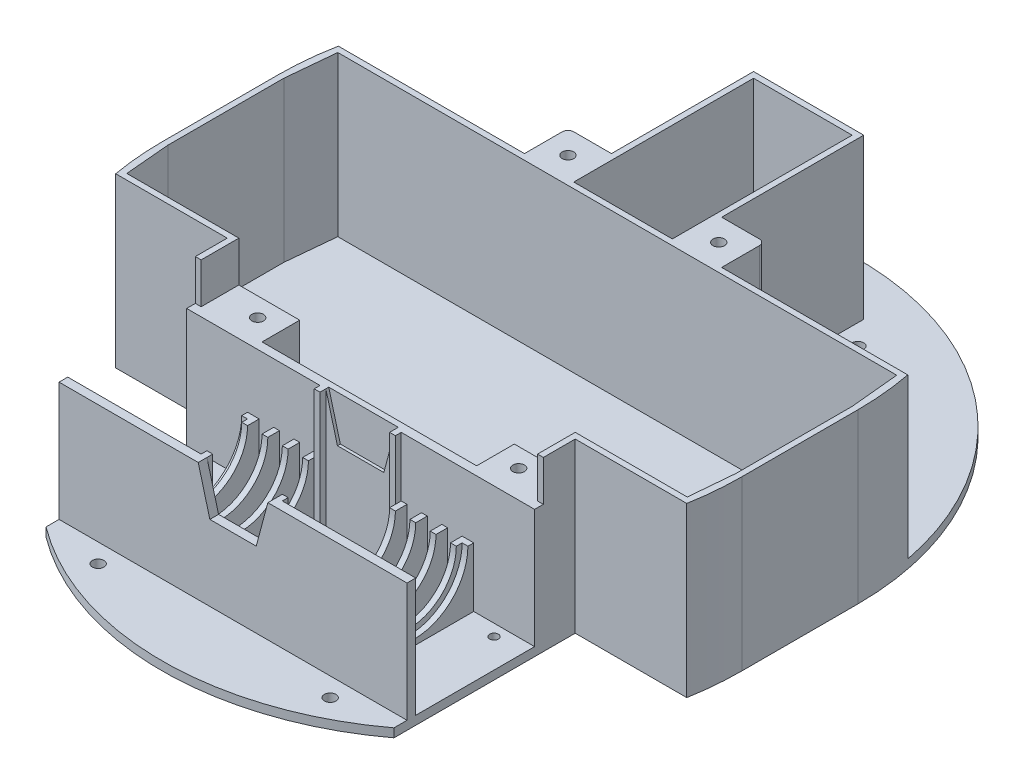
from build123d import *

# Parameters (mm, degrees)
EXTRUDE_1271_DEPTH           = 3
CUT_EXTRUDE_1634_DEPTH       = 3
SKETCH_3_W                   = 34
SKETCH_3_H                   = 62
CUT_EXTRUDE_1874_DEPTH       = 3
SKETCH_4_W                   = 120
SKETCH_4_H                   = 3
EXTRUDE_2348_DEPTH           = 41
SKETCH_5_W                   = 4
SKETCH_5_H                   = 41
SKETCH_5_W_2                 = 2
EXTRUDE_3692_DEPTH           = 20.5
SKETCH_10_R                  = 1.5
CUT_EXTRUDE_4123_DEPTH       = 177.864354803
CUT_EXTRUDE_4368_DEPTH       = 2
CUT_EXTRUDE_4605_DEPTH       = 2
SKETCH_11_R                  = 16.5
CUT_EXTRUDE_4720_DEPTH       = 23
SKETCH_12_R                  = 16.5
CUT_EXTRUDE_4849_DEPTH       = 23
CUT_EXTRUDE_5113_DEPTH       = 45
SKETCH_14_W                  = 2
SKETCH_14_H                  = 2
EXTRUDE_5954_DEPTH           = 41
SKETCH_19_W                  = 5
SKETCH_19_H                  = 41
CUT_EXTRUDE_6417_DEPTH       = 3
EXTRUDE_8763_DEPTH           = 55
EXTRUDE_9330_DEPTH           = 55
EXTRUDE_9736_DEPTH           = 2
EXTRUDE_10110_DEPTH          = 2
SKETCH_22_R                  = 2.5
CUT_EXTRUDE_10276_DEPTH      = 42
EXTRUDE_10908_DEPTH          = 55
SKETCH_26_W                  = 21
SKETCH_26_H                  = 13
EXTRUDE_11207_DEPTH          = 41
SKETCH_23_R                  = 2
CUT_EXTRUDE_12071_DEPTH      = 55
CUT_EXTRUDE_12071_DEPTH_BACK = 3


with BuildPart() as part:
    # 草图1 → Extrude 1271 (new body)
    with BuildSketch(Plane(origin=(0, 0, 0), x_dir=(1, 0, 0), z_dir=(0, 1, 0))):
        with BuildLine():
            ThreePointArc((-97.979589711, 20), (-99.493615301, 10.050896201), (-100, 0))
            Line((-100, 0), (-91.651513899, 0))
            ThreePointArc((-91.651513899, 0), (-95.341433092, 9.833609167), (-97.979589711, 20))
        make_face()
        with BuildLine():
            Line((-91.651513899, 0), (-100, 0))
            ThreePointArc((-100, 0), (0, -100), (100, 0))
            Line((100, 0), (91.651513899, 0))
            ThreePointArc((91.651513899, 0), (0, -60), (-91.651513899, 0))
        make_face()
        with BuildLine():
            Line((91.651513899, 0), (100, 0))
            ThreePointArc((100, 0), (99.493615301, 10.050896201), (97.979589711, 20))
            ThreePointArc((97.979589711, 20), (95.341433092, 9.833609167), (91.651513899, 0))
        make_face()
        with BuildLine():
            ThreePointArc((-97.979589711, 20), (-95.341433092, 9.833609167), (-91.651513899, 0))
            Line((-91.651513899, 0), (91.651513899, 0))
            ThreePointArc((91.651513899, 0), (95.341433092, 9.833609167), (97.979589711, 20))
            ThreePointArc((97.979589711, 20), (95.341433092, 30.166390833), (91.651513899, 40))
            Line((91.651513899, 40), (-91.651513899, 40))
            ThreePointArc((-91.651513899, 40), (-95.341433092, 30.166390833), (-97.979589711, 20))
        make_face()
        with BuildLine():
            ThreePointArc((100, 40), (0, 140), (-100, 40))
            Line((-100, 40), (-91.651513899, 40))
            ThreePointArc((-91.651513899, 40), (0, 100), (91.651513899, 40))
            Line((91.651513899, 40), (100, 40))
        make_face()
        with BuildLine():
            Line((-91.651513899, 40), (-100, 40))
            ThreePointArc((-100, 40), (-99.493615301, 29.949103799), (-97.979589711, 20))
            ThreePointArc((-97.979589711, 20), (-95.341433092, 30.166390833), (-91.651513899, 40))
        make_face()
        with BuildLine():
            ThreePointArc((97.979589711, 20), (99.493615301, 29.949103799), (100, 40))
            Line((100, 40), (91.651513899, 40))
            ThreePointArc((91.651513899, 40), (95.341433092, 30.166390833), (97.979589711, 20))
        make_face()
        with BuildLine():
            ThreePointArc((91.651513899, 40), (0, 100), (-91.651513899, 40))
            Line((-91.651513899, 40), (91.651513899, 40))
        make_face()
        with BuildLine():
            Line((91.651513899, 0), (-91.651513899, 0))
            ThreePointArc((-91.651513899, 0), (0, -60), (91.651513899, 0))
        make_face()
        with BuildLine():
            ThreePointArc((97.979589711, 20), (99.493615301, 10.050896201), (100, 0))
            Line((100, 0), (100, 40))
            ThreePointArc((100, 40), (99.493615301, 29.949103799), (97.979589711, 20))
        make_face()
        with BuildLine():
            Line((-100, 40), (-100, 0))
            ThreePointArc((-100, 0), (-99.493615301, 10.050896201), (-97.979589711, 20))
            ThreePointArc((-97.979589711, 20), (-99.493615301, 29.949103799), (-100, 40))
        make_face()
    extrude(amount=EXTRUDE_1271_DEPTH)

    # 草图2 → Cut-Extrude 1634 (cut)
    with BuildSketch(Plane(origin=(0, 3, 0), x_dir=(1, 0, 0), z_dir=(0, 1, 0))):
        with BuildLine():
            ThreePointArc((-98.456843338, -17.5), (-85.168687322, -52.40510185), (-60, -80))
            Line((-60, -80), (-60, -17.5))
            Line((-60, -17.5), (-98.456843338, -17.5))
        make_face()
        with BuildLine():
            Line((98.456843338, -17.5), (60, -17.5))
            Line((60, -17.5), (60, -80))
            ThreePointArc((60, -80), (85.168687322, -52.40510185), (98.456843338, -17.5))
        make_face()
    extrude(amount=-CUT_EXTRUDE_1634_DEPTH, mode=Mode.SUBTRACT)

    # 草图3 → Cut-Extrude 1874 (cut)
    with BuildSketch(Plane(origin=(0, 3, 0), x_dir=(1, 0, 0), z_dir=(0, 1, 0))):
        with Locations((0, 90)):
            Rectangle(SKETCH_3_W, SKETCH_3_H)
    extrude(amount=-CUT_EXTRUDE_1874_DEPTH, mode=Mode.SUBTRACT)

    # 草图4 → Extrude 2348 (add)
    with BuildSketch(Plane(origin=(0, 3, 0), x_dir=(1, 0, 0), z_dir=(0, 1, 0))):
        with Locations((0, -74)):
            Rectangle(SKETCH_4_W, SKETCH_4_H)
        with Locations((0, -30)):
            Rectangle(SKETCH_4_W, SKETCH_4_H)
    extrude(amount=EXTRUDE_2348_DEPTH)

    # 草图5 → Extrude 3692 (add)
    with BuildSketch(Plane(origin=(0, 3, 0), x_dir=(1, 0, 0), z_dir=(0, 1, 0))):
        with Locations((-37, -52)):
            Rectangle(SKETCH_5_W, SKETCH_5_H)
        with Locations((37, -52)):
            Rectangle(SKETCH_5_W, SKETCH_5_H)
        with Locations((-22, -52)):
            Rectangle(SKETCH_5_W_2, SKETCH_5_H)
        with Locations((-15, -52)):
            Rectangle(SKETCH_5_W_2, SKETCH_5_H)
        with Locations((22, -52)):
            Rectangle(SKETCH_5_W_2, SKETCH_5_H)
        with Locations((29, -52)):
            Rectangle(SKETCH_5_W_2, SKETCH_5_H)
        with Locations((-29, -52)):
            Rectangle(SKETCH_5_W_2, SKETCH_5_H)
        with Locations((15, -52)):
            Rectangle(SKETCH_5_W_2, SKETCH_5_H)
    extrude(amount=EXTRUDE_3692_DEPTH)

    # 草图10 → Cut-Extrude 4123 (cut, through all)
    with BuildSketch(Plane(origin=(0, 3, 0), x_dir=(1, 0, 0), z_dir=(0, 1, 0))):
        with Locations(Location((-50, -35.5, 0), (0, 0, 270))):
            Circle(SKETCH_10_R)
        with Locations(Location((-50, -68.5, 0), (0, 0, 270))):
            Circle(SKETCH_10_R)
        with Locations(Location((50, -35.5, 0), (0, 0, 270))):
            Circle(SKETCH_10_R)
        with Locations(Location((50, -68.5, 0), (0, 0, 270))):
            Circle(SKETCH_10_R)
    extrude(amount=-CUT_EXTRUDE_4123_DEPTH, mode=Mode.SUBTRACT)

    # 草图6 → Cut-Extrude 4368 (cut)
    with BuildSketch(Plane.ZY.offset(39)):
        with BuildLine():
            Line((33.5, 23.5), (70.5, 23.5))
            ThreePointArc((70.5, 23.5), (52, 42), (33.5, 23.5))
        make_face()
        with BuildLine():
            ThreePointArc((33.5, 23.5), (52, 5), (70.5, 23.5))
            Line((70.5, 23.5), (33.5, 23.5))
        make_face()
    extrude(amount=-CUT_EXTRUDE_4368_DEPTH, mode=Mode.SUBTRACT)

    # 草图8 → Cut-Extrude 4605 (cut)
    with BuildSketch(Plane(origin=(39, 0, 0), x_dir=(0, 0, -1), z_dir=(1, 0, 0))):
        with BuildLine():
            Line((-70.5, 23.5), (-33.5, 23.5))
            ThreePointArc((-33.5, 23.5), (-52, 42), (-70.5, 23.5))
        make_face()
        with BuildLine():
            ThreePointArc((-70.5, 23.5), (-52, 5), (-33.5, 23.5))
            Line((-33.5, 23.5), (-70.5, 23.5))
        make_face()
    extrude(amount=-CUT_EXTRUDE_4605_DEPTH, mode=Mode.SUBTRACT)

    # 草图11 → Cut-Extrude 4720 (cut)
    with BuildSketch(Plane.ZY.offset(37)):
        with Locations((52, 23.5)):
            Circle(SKETCH_11_R)
    extrude(amount=-CUT_EXTRUDE_4720_DEPTH, mode=Mode.SUBTRACT)

    # 草图12 → Cut-Extrude 4849 (cut)
    with BuildSketch(Plane(origin=(37, 0, 0), x_dir=(0, 0, -1), z_dir=(1, 0, 0))):
        with Locations((-52, 23.5)):
            Circle(SKETCH_12_R)
    extrude(amount=-CUT_EXTRUDE_4849_DEPTH, mode=Mode.SUBTRACT)

    # 草图13 → Cut-Extrude 5113 (cut)
    with BuildSketch(Plane.XY.offset(75.5)):
        Polygon((-8, 29), (8, 29), (12, 44), (-12, 44), align=None)
    extrude(amount=-CUT_EXTRUDE_5113_DEPTH, mode=Mode.SUBTRACT)

    # 草图14 → Extrude 5954 (add)
    with BuildSketch(Plane(origin=(0, 3, 0), x_dir=(1, 0, 0), z_dir=(0, 1, 0))):
        with Locations((-13, -32.5)):
            Rectangle(SKETCH_14_W, SKETCH_14_H)
        with Locations((13, -32.5)):
            Rectangle(SKETCH_14_W, SKETCH_14_H)
        with Locations((13, -71.5)):
            Rectangle(SKETCH_14_W, SKETCH_14_H)
        with Locations((-13, -71.5)):
            Rectangle(SKETCH_14_W, SKETCH_14_H)
    extrude(amount=EXTRUDE_5954_DEPTH)

    # 草图19 → Cut-Extrude 6417 (cut)
    with BuildSketch(Plane(origin=(0, 3, 0), x_dir=(1, 0, 0), z_dir=(0, 1, 0))):
        with Locations((-32.5, -52)):
            Rectangle(SKETCH_19_W, SKETCH_19_H)
        with Locations((-25.5, -52)):
            Rectangle(SKETCH_19_W, SKETCH_19_H)
        with Locations((-18.5, -52)):
            Rectangle(SKETCH_19_W, SKETCH_19_H)
        with Locations((18.5, -52)):
            Rectangle(SKETCH_19_W, SKETCH_19_H)
        with Locations((25.5, -52)):
            Rectangle(SKETCH_19_W, SKETCH_19_H)
        with Locations((32.5, -52)):
            Rectangle(SKETCH_19_W, SKETCH_19_H)
    extrude(amount=-CUT_EXTRUDE_6417_DEPTH, mode=Mode.SUBTRACT)

    # 草图15 → Extrude 8763 (add)
    with BuildSketch(Plane(origin=(0, 3, 0), x_dir=(1, 0, 0), z_dir=(0, 1, 0))):
        with BuildLine():
            Line((-96.633204099, -15.5), (-98, 0))
            Line((-98, 0), (-98, 40))
            Line((-98, 40), (-96.370155449, 57))
            Line((-96.370155449, 57), (96.370155449, 57))
            Line((96.370155449, 57), (98, 40))
            Line((98, 40), (98, 0))
            Line((98, 0), (96.633204099, -15.5))
            Line((96.633204099, -15.5), (58, -15.5))
            Line((58, -15.5), (58, -28.5))
            Line((58, -28.5), (60, -28.5))
            Line((60, -28.5), (60, -17.5))
            Line((60, -17.5), (98.456843338, -17.5))
            ThreePointArc((98.456843338, -17.5), (99.613463783, -8.78395316), (100, 0))
            Line((100, 0), (100, 40))
            ThreePointArc((100, 40), (99.543560573, 49.543560573), (98.178409032, 59))
            Line((98.178409032, 59), (-98.178409032, 59))
            ThreePointArc((-98.178409032, 59), (-99.543560573, 49.543560573), (-100, 40))
            Line((-100, 40), (-100, 0))
            ThreePointArc((-100, 0), (-99.613463783, -8.78395316), (-98.456843338, -17.5))
            Line((-98.456843338, -17.5), (-60, -17.5))
            Line((-60, -17.5), (-60, -28.5))
            Line((-60, -28.5), (-58, -28.5))
            Line((-58, -28.5), (-58, -15.5))
            Line((-58, -15.5), (-96.633204099, -15.5))
        make_face()
    extrude(amount=EXTRUDE_8763_DEPTH)

    # 草图16 → Extrude 9330 (add)
    with BuildSketch(Plane(origin=(0, 3, 0), x_dir=(1, 0, 0), z_dir=(0, 1, 0))):
        Polygon((-19, 123), (-19, 59), (-17, 59), (-17, 121), (17, 121), (17, 59), (19, 59), (19, 123), align=None)
    extrude(amount=EXTRUDE_9330_DEPTH)

    # 草图20 → Extrude 9736 (add)
    with BuildSketch(Plane.ZY.offset(19)):
        with BuildLine():
            ThreePointArc((-82.5, 13), (-90, 20.5), (-97.5, 13))
            Line((-97.5, 13), (-82.5, 13))
        make_face()
        with BuildLine():
            Line((-82.5, 13), (-97.5, 13))
            ThreePointArc((-97.5, 13), (-90, 5.5), (-82.5, 13))
        make_face()
        with BuildLine():
            ThreePointArc((-82.5, 13), (-90, 5.5), (-97.5, 13))
            Line((-97.5, 13), (-97.5, 3))
            Line((-97.5, 3), (-82.5, 3))
            Line((-82.5, 3), (-82.5, 13))
        make_face()
    extrude(amount=EXTRUDE_9736_DEPTH)

    # 草图21 → Extrude 10110 (add)
    with BuildSketch(Plane(origin=(19, 0, 0), x_dir=(0, 0, -1), z_dir=(1, 0, 0))):
        with BuildLine():
            ThreePointArc((97.5, 13), (90, 20.5), (82.5, 13))
            Line((82.5, 13), (97.5, 13))
        make_face()
        with BuildLine():
            Line((97.5, 13), (82.5, 13))
            ThreePointArc((82.5, 13), (90, 5.5), (97.5, 13))
        make_face()
        with BuildLine():
            ThreePointArc((97.5, 13), (90, 5.5), (82.5, 13))
            Line((82.5, 13), (82.5, 3))
            Line((82.5, 3), (97.5, 3))
            Line((97.5, 3), (97.5, 13))
        make_face()
    extrude(amount=EXTRUDE_10110_DEPTH)

    # 草图22 → Cut-Extrude 10276 (cut)
    with BuildSketch(Plane.ZY.offset(21)):
        with Locations((-90, 13)):
            Circle(SKETCH_22_R)
    extrude(amount=-CUT_EXTRUDE_10276_DEPTH, mode=Mode.SUBTRACT)

    # 草图25 → Extrude 10908 (add)
    with BuildSketch(Plane(origin=(0, 3, 0), x_dir=(1, 0, 0), z_dir=(0, 1, 0))):
        with BuildLine():
            Line((-19, 59), (-34, 59))
            Line((-34, 59), (-34, 72))
            ThreePointArc((-34, 72), (-33.414213562, 73.414213562), (-32, 74))
            Line((-32, 74), (-19, 74))
            Line((-19, 74), (-19, 59))
        make_face()
        with BuildLine():
            Line((19, 59), (34, 59))
            Line((34, 59), (34, 72))
            ThreePointArc((34, 72), (33.414213562, 73.414213562), (32, 74))
            Line((32, 74), (19, 74))
            Line((19, 74), (19, 59))
        make_face()
    extrude(amount=EXTRUDE_10908_DEPTH)

    # 草图26 → Extrude 11207 (add)
    with BuildSketch(Plane(origin=(0, 3, 0), x_dir=(1, 0, 0), z_dir=(0, 1, 0))):
        with Locations((-47.5, -22)):
            Rectangle(SKETCH_26_W, SKETCH_26_H)
        with Locations((47.5, -22)):
            Rectangle(SKETCH_26_W, SKETCH_26_H)
    extrude(amount=EXTRUDE_11207_DEPTH)

    # 草图23 → Cut-Extrude 12071 (cut, two sides)
    with BuildSketch(Plane(origin=(0, 3, 0), x_dir=(1, 0, 0), z_dir=(0, 1, 0))) as cut_extrude_12071_sk:
        with Locations(Location((-88, 66, 0), (0, 0, 270))):
            Circle(SKETCH_23_R)
        with Locations(Location((-26, 66, 0), (0, 0, 270))):
            Circle(SKETCH_23_R)
        with Locations(Location((26, 66, 0), (0, 0, 270))):
            Circle(SKETCH_23_R)
        with Locations(Location((88, 66, 0), (0, 0, 270))):
            Circle(SKETCH_23_R)
        with Locations(Location((-45, -22, 0), (0, 0, 270))):
            Circle(SKETCH_23_R)
        with Locations(Location((45, -22, 0), (0, 0, 270))):
            Circle(SKETCH_23_R)
        with Locations(Location((-40, -82, 0), (0, 0, 270))):
            Circle(SKETCH_23_R)
        with Locations(Location((40, -82, 0), (0, 0, 270))):
            Circle(SKETCH_23_R)
        with Locations(Location((-26, 114, 0), (0, 0, 270))):
            Circle(SKETCH_23_R)
        with Locations(Location((26, 114, 0), (0, 0, 270))):
            Circle(SKETCH_23_R)
    extrude(amount=CUT_EXTRUDE_12071_DEPTH, mode=Mode.SUBTRACT)
    extrude(cut_extrude_12071_sk.sketch, amount=-CUT_EXTRUDE_12071_DEPTH_BACK, mode=Mode.SUBTRACT)


solid = part.part
